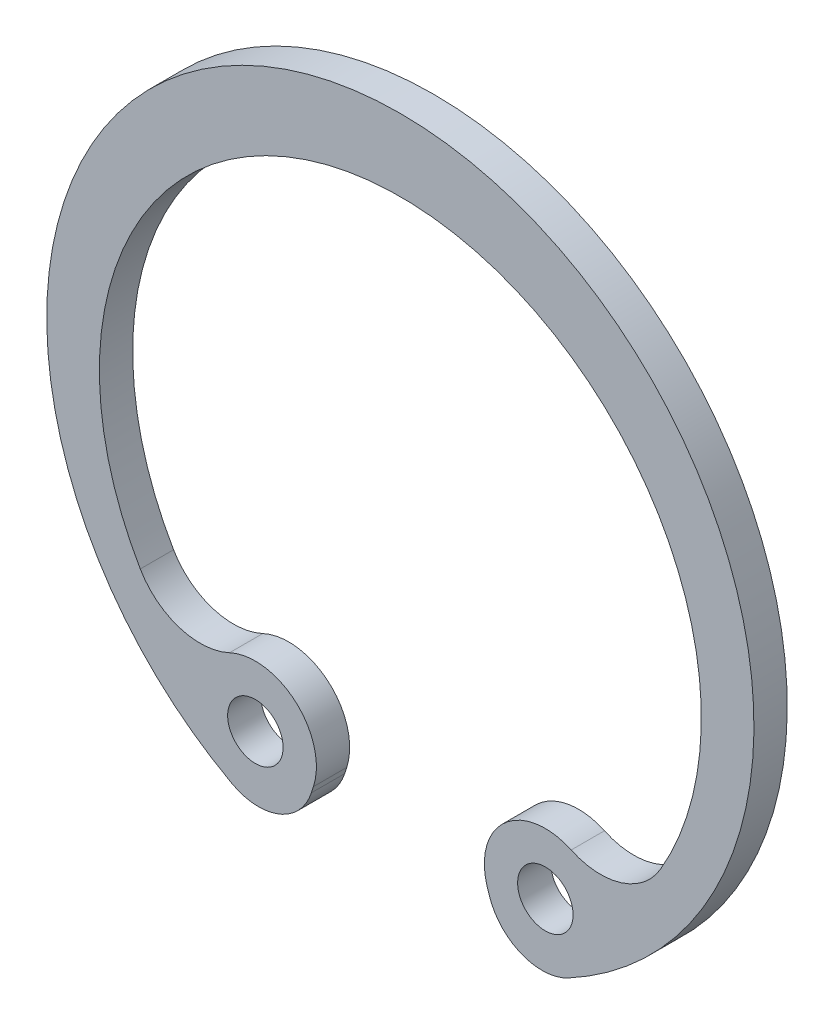
from build123d import *

# Parameters (mm, degrees)
SKETCH_3_R      = 1
EXTRUDE_1_DEPTH = 1.2


with BuildPart() as part:
    # Эскиз3 → Бобышка-Вытянуть1 (new body)
    with BuildSketch(Plane.XY):
        with BuildLine():
            Line((-3.208591813, -10.070429847), (-3.13392227, -9.838843592))
            ThreePointArc((-3.13392227, -9.838843592), (-3.772590397, -7.513749153), (-6.159272929, -7.170663716))
            ThreePointArc((-6.159272929, -7.170663716), (-7.964052136, -7.291836988), (-9.378160244, -6.16391447))
            ThreePointArc((-9.378160244, -6.16391447), (0, 10.15), (9.378160244, -6.16391447))
            ThreePointArc((9.378160244, -6.16391447), (7.964052136, -7.291836988), (6.159272929, -7.170663716))
            ThreePointArc((6.159272929, -7.170663716), (3.772590397, -7.513749153), (3.13392227, -9.838843592))
            Line((3.13392227, -9.838843592), (3.208591813, -10.070429847))
            ThreePointArc((3.208591813, -10.070429847), (4.367179244, -11.312788363), (6.063182163, -11.216074271))
            ThreePointArc((6.063182163, -11.216074271), (0, 12.75), (-6.063182163, -11.216074271))
            ThreePointArc((-6.063182163, -11.216074271), (-4.367179244, -11.312788363), (-3.208591813, -10.070429847))
        make_face()
        with Locations((-5.227775517, -9.163729839)):
            Circle(SKETCH_3_R, mode=Mode.SUBTRACT)
        with Locations((5.227775517, -9.163729839)):
            Circle(SKETCH_3_R, mode=Mode.SUBTRACT)
    extrude(amount=EXTRUDE_1_DEPTH)


solid = part.part
